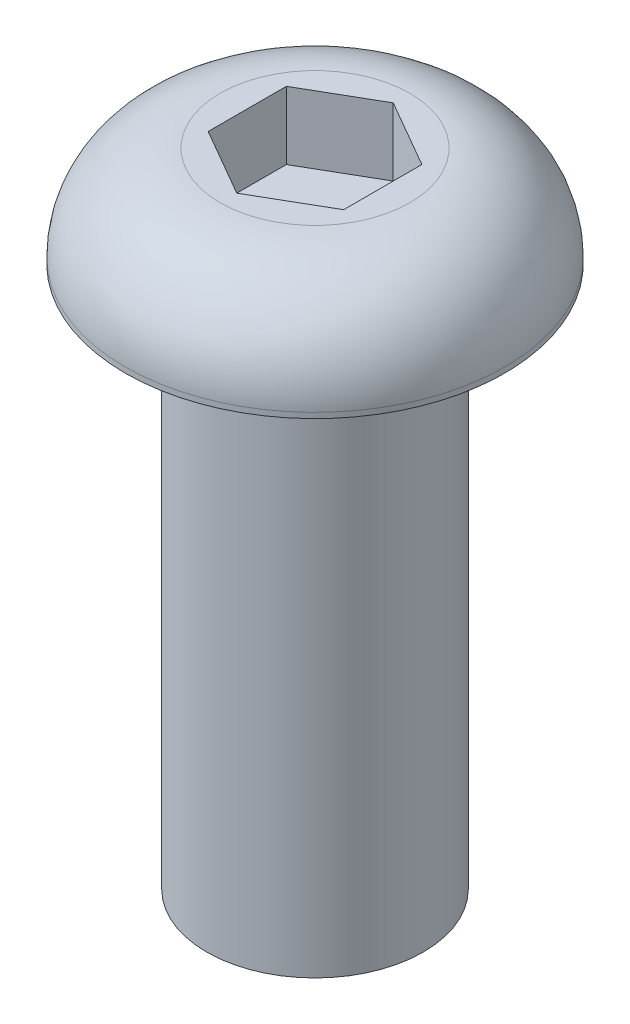
from build123d import *

# Parameters (mm, degrees)
CORTE_EXTRUS_O1_DEPTH = 5


with BuildPart() as part:
    # Esboço1 → Revolução1 (revolve)
    with BuildSketch(Plane.XY):
        with BuildLine():
            Line((0, 0), (8, 0))
            Line((8, 0), (8, 40))
            Line((8, 40), (14, 40))
            Line((14, 40), (14, 40.4))
            ThreePointArc((14, 40.4), (11.949747468, 45.349747468), (7, 47.4))
            Line((7, 47.4), (0, 47.4))
            Line((0, 47.4), (0, 0))
        make_face()
    revolve(axis=Axis((0, 47.4, 0), (0, -1, 0)))

    # Esboço2 → Corte-extrusão1 (cut)
    with BuildSketch(Plane(origin=(0, 47.4, 0), x_dir=(1, 0, 0), z_dir=(0, 1, 0))):
        Polygon((0, 5.773502692), (-5, 2.886751346), (-5, -2.886751346), (0, -5.773502692), (5, -2.886751346), (5, 2.886751346), align=None)
    extrude(amount=-CORTE_EXTRUS_O1_DEPTH, mode=Mode.SUBTRACT)


solid = part.part
